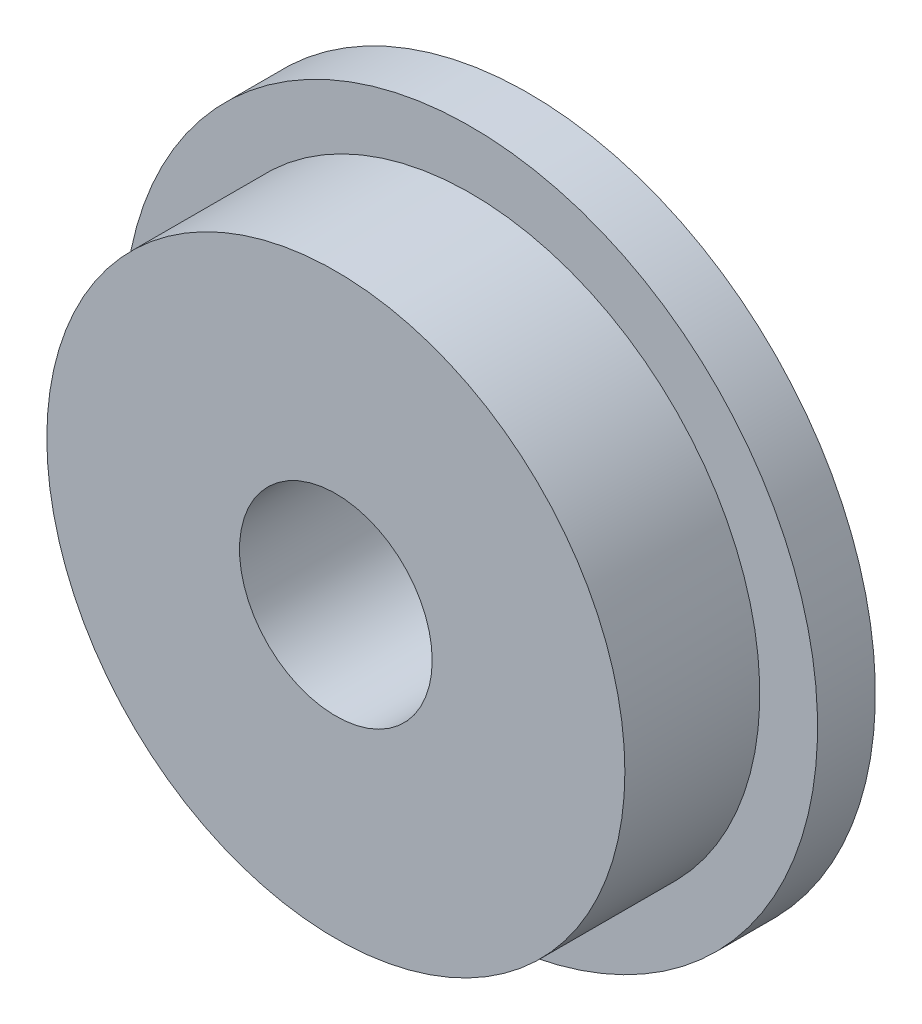
from build123d import *

# Parameters (mm, degrees)
SKETCH_1_R               = 3
EXTRUDE_1_DEPTH          = 2
SKETCH_3_R               = 3.6
EXTRUDE_2_DEPTH          = 0.6
SKETCH_4_R               = 1
CUT_EXTRUDE_1_DEPTH      = 1
CUT_EXTRUDE_1_DEPTH_BACK = 3


with BuildPart() as part:
    # Эскиз1 → Бобышка-Вытянуть1 (new body)
    with BuildSketch(Plane.XY):
        Circle(SKETCH_1_R)
    extrude(amount=EXTRUDE_1_DEPTH)

    # Эскиз3 → Бобышка-Вытянуть2 (add)
    with BuildSketch(Plane(origin=(0, 0, 0), x_dir=(-1, 0, 0), z_dir=(0, 0, -1))):
        Circle(SKETCH_3_R)
    extrude(amount=-EXTRUDE_2_DEPTH)

    # Эскиз4 → Вырез-Вытянуть1 (cut, two sides)
    with BuildSketch(Plane.XY.offset(2)) as cut_extrude_1_sk:
        Circle(SKETCH_4_R)
    extrude(amount=CUT_EXTRUDE_1_DEPTH, mode=Mode.SUBTRACT)
    extrude(cut_extrude_1_sk.sketch, amount=-CUT_EXTRUDE_1_DEPTH_BACK, mode=Mode.SUBTRACT)


solid = part.part
